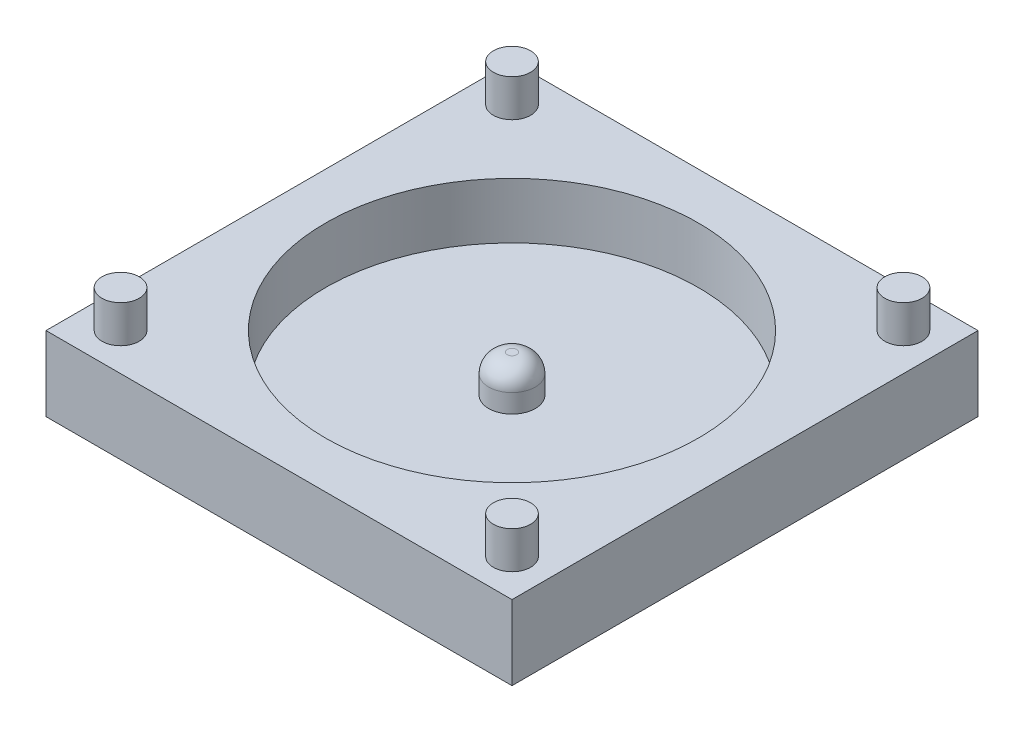
from build123d import *

# Parameters (mm, degrees)
SKETCH1_W           = 25
SKETCH1_H           = 25
BOSS_EXTRUDE1_DEPTH = 4
SKETCH2_R           = 10
CUT_EXTRUDE1_DEPTH  = 3
SKETCH3_R           = 1.25
BOSS_EXTRUDE2_DEPTH = 2
FILLET1_R           = 1
SKETCH4_R           = 1
BOSS_EXTRUDE3_DEPTH = 2


with BuildPart() as part:
    # Sketch1 → Boss-Extrude1 (new body)
    with BuildSketch(Plane(origin=(0, 0, 0), x_dir=(1, 0, 0), z_dir=(0, 1, 0))):
        Rectangle(SKETCH1_W, SKETCH1_H)
    extrude(amount=BOSS_EXTRUDE1_DEPTH)

    # Sketch2 → Cut-Extrude1 (cut)
    with BuildSketch(Plane(origin=(0, 4, 0), x_dir=(1, 0, 0), z_dir=(0, 1, 0))):
        Circle(SKETCH2_R)
    extrude(amount=-CUT_EXTRUDE1_DEPTH, mode=Mode.SUBTRACT)

    # Sketch3 → Boss-Extrude2 (add)
    with BuildSketch(Plane(origin=(0, 1, 0), x_dir=(1, 0, 0), z_dir=(0, 1, 0))):
        Circle(SKETCH3_R)
    extrude(amount=BOSS_EXTRUDE2_DEPTH)

    # Fillet1
    fillet1_edges = [part.edges().sort_by_distance(p)[0] for p in [
        (-1.25, 3, 0),
    ]]
    fillet(fillet1_edges, radius=FILLET1_R)

    # Sketch4 → Boss-Extrude3 (add)
    with BuildSketch(Plane(origin=(0, 4, 0), x_dir=(1, 0, 0), z_dir=(0, 1, 0))):
        with Locations((-10.5, 10.5)):
            Circle(SKETCH4_R)
        with Locations((10.5, 10.5)):
            Circle(SKETCH4_R)
        with Locations((10.5, -10.5)):
            Circle(SKETCH4_R)
        with Locations((-10.5, -10.5)):
            Circle(SKETCH4_R)
    extrude(amount=BOSS_EXTRUDE3_DEPTH)


solid = part.part
